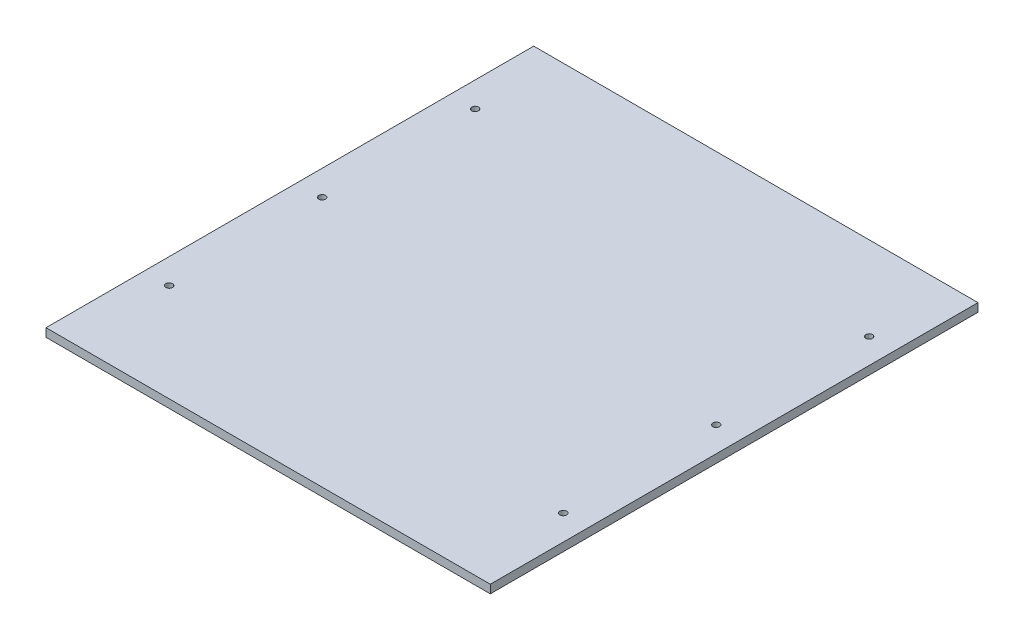
from build123d import *

# Parameters (mm, degrees)
SKETCH1_W           = 265.28
SKETCH1_H           = 291.2
BOSS_EXTRUDE1_DEPTH = 5
SKETCH3_R           = 2
CUT_EXTRUDE1_DEPTH  = 5


with BuildPart() as part:
    # Sketch1 → Boss-Extrude1 (new body)
    with BuildSketch(Plane(origin=(0, 0, 0), x_dir=(1, 0, 0), z_dir=(0, 1, 0))):
        with Locations((-6.964705882, -4.282352941)):
            Rectangle(SKETCH1_W, SKETCH1_H)
    extrude(amount=BOSS_EXTRUDE1_DEPTH)

    # Sketch3 → Cut-Extrude1 (cut)
    with BuildSketch(Plane(origin=(0, 5, 0), x_dir=(1, 0, 0), z_dir=(0, 1, 0))):
        with Locations((-124.604705882, 91.317647059)):
            Circle(SKETCH3_R)
        with Locations((-124.604705882, 0)):
            Circle(SKETCH3_R)
        with Locations((-124.604705882, -91.317647059)):
            Circle(SKETCH3_R)
        with Locations((110.675294118, 91.317647059)):
            Circle(SKETCH3_R)
        with Locations((110.675294118, 0)):
            Circle(SKETCH3_R)
        with Locations((110.675294118, -91.317647059)):
            Circle(SKETCH3_R)
    extrude(amount=-CUT_EXTRUDE1_DEPTH, mode=Mode.SUBTRACT)


solid = part.part
